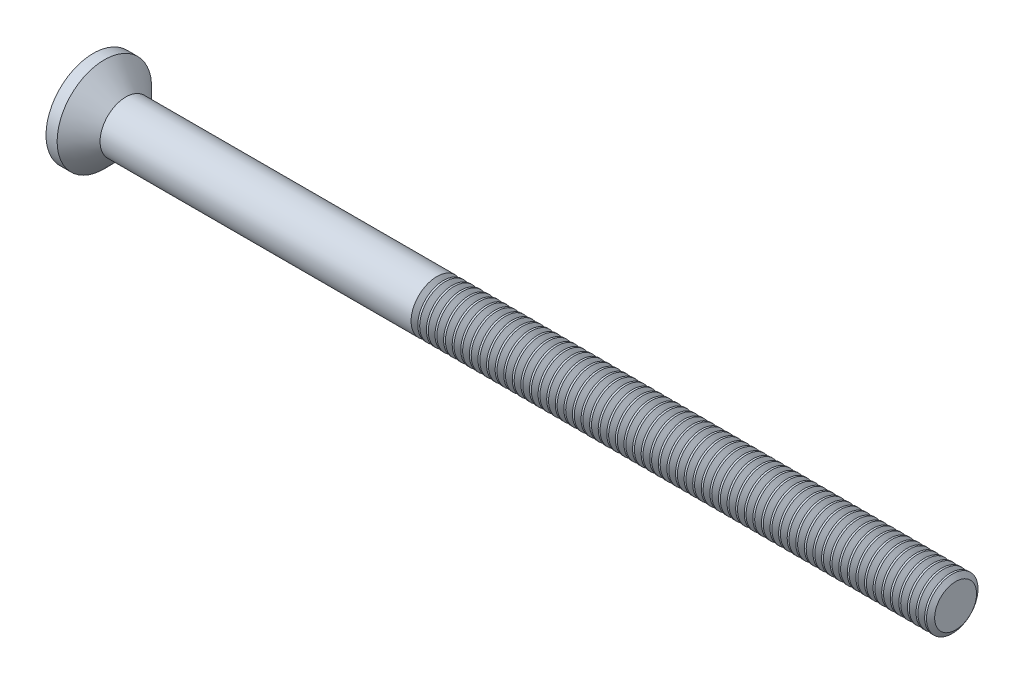
from build123d import *

# Parameters (mm, degrees)
SKETCH3_W         = 0.83
SKETCH3_H         = 3.44
SKETCH4_W         = 0.415
SKETCH4_H         = 0.415
CIRPATTERN1_COUNT = 2
CIRPATTERN1_ANGLE = 90
THDSCHPAT_COUNT   = 61
THDSCHPAT_PITCH   = 0.5


with BuildPart() as part:
    # BodySke → Base-Revolve (revolve)
    with BuildSketch(Plane.XY):
        with BuildLine():
            Line((0, 0), (50.727669073, 0))
            Line((50.727669073, 0), (50.727669073, 1.5))
            Line((50.727669073, 1.5), (2.427669073, 1.5))
            Line((2.427669073, 1.5), (1.177669073, 2.75))
            Line((1.177669073, 2.75), (0.529956332, 2.75))
            ThreePointArc((0.529956332, 2.75), (0.133696843, 1.400299407), (0, 0))
        make_face()
    revolve(axis=Axis((-15.875, 0, 0), (1, 0, 0)))

    # Sketch3 → Cross section 0
    with BuildSketch(Plane(origin=(0, 0, 0), x_dir=(0, 0, -1), z_dir=(1, 0, 0))):
        Rectangle(SKETCH3_W, SKETCH3_H)
    # Sketch4 → Cross section 1
    with BuildSketch(Plane(origin=(2.33, 0, 0), x_dir=(0, 0, -1), z_dir=(1, 0, 0))):
        Rectangle(SKETCH4_W, SKETCH4_H)
    cross = loft(mode=Mode.SUBTRACT)

    # CirPattern1: Cross ×2 about axis
    cirpattern1_axis = Axis((0, 0, 0), (1, 0, 0))
    for i in range(1, CIRPATTERN1_COUNT):
        add(cross.rotate(cirpattern1_axis, i * CIRPATTERN1_ANGLE / (CIRPATTERN1_COUNT - 1)), mode=Mode.SUBTRACT)

    # ThdSchSke → ThreadSchematic (revolve, cut)
    with BuildSketch(Plane.XY):
        Polygon((20.727669073, -1.2195), (20.531260858, -1.5), (20.531260858, -1.875), (20.924077287, -1.875), (20.924077287, -1.5), align=None)
    threadschematic = revolve(axis=Axis((-3.175, 0, 0), (1, 0, 0)), mode=Mode.SUBTRACT)

    # ThdSchPat: ThreadSchematic ×61
    with Locations(*[(i * THDSCHPAT_PITCH, 0, 0) for i in range(1, THDSCHPAT_COUNT)]):
        add(threadschematic, mode=Mode.SUBTRACT)


solid = part.part
